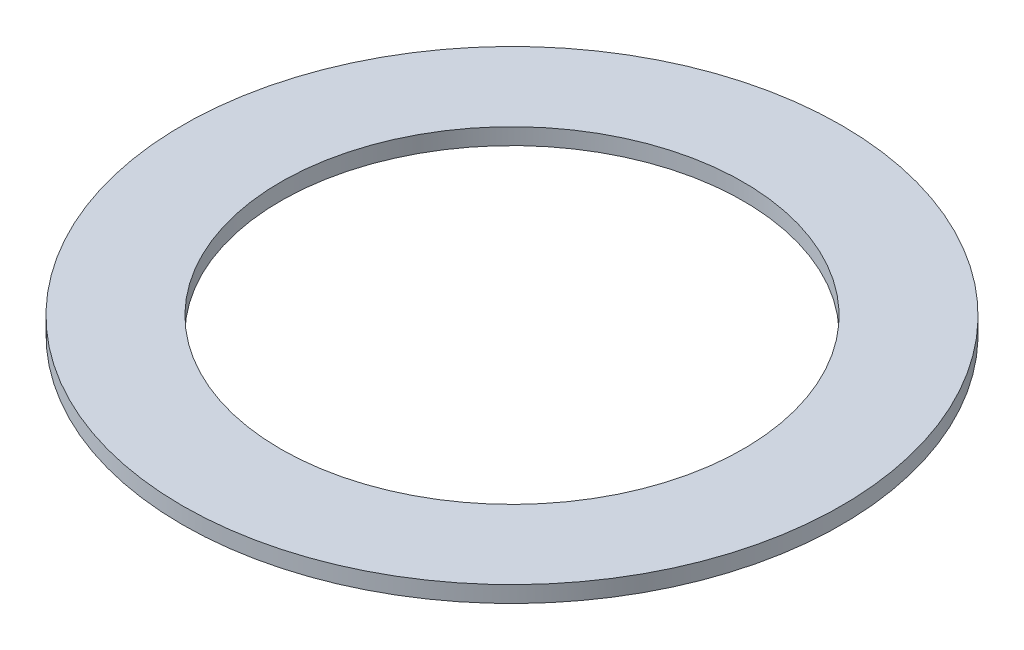
from build123d import *

# Parameters (mm, degrees)
SKETCH1_R           = 100.625
SKETCH1_R_2         = 70.625
BOSS_EXTRUDE1_DEPTH = 5


with BuildPart() as part:
    # Sketch1 → Boss-Extrude1 (new body)
    with BuildSketch(Plane(origin=(0, 0, 0), x_dir=(1, 0, 0), z_dir=(0, 1, 0))):
        Circle(SKETCH1_R)
        Circle(SKETCH1_R_2, mode=Mode.SUBTRACT)
    extrude(amount=BOSS_EXTRUDE1_DEPTH)


solid = part.part
